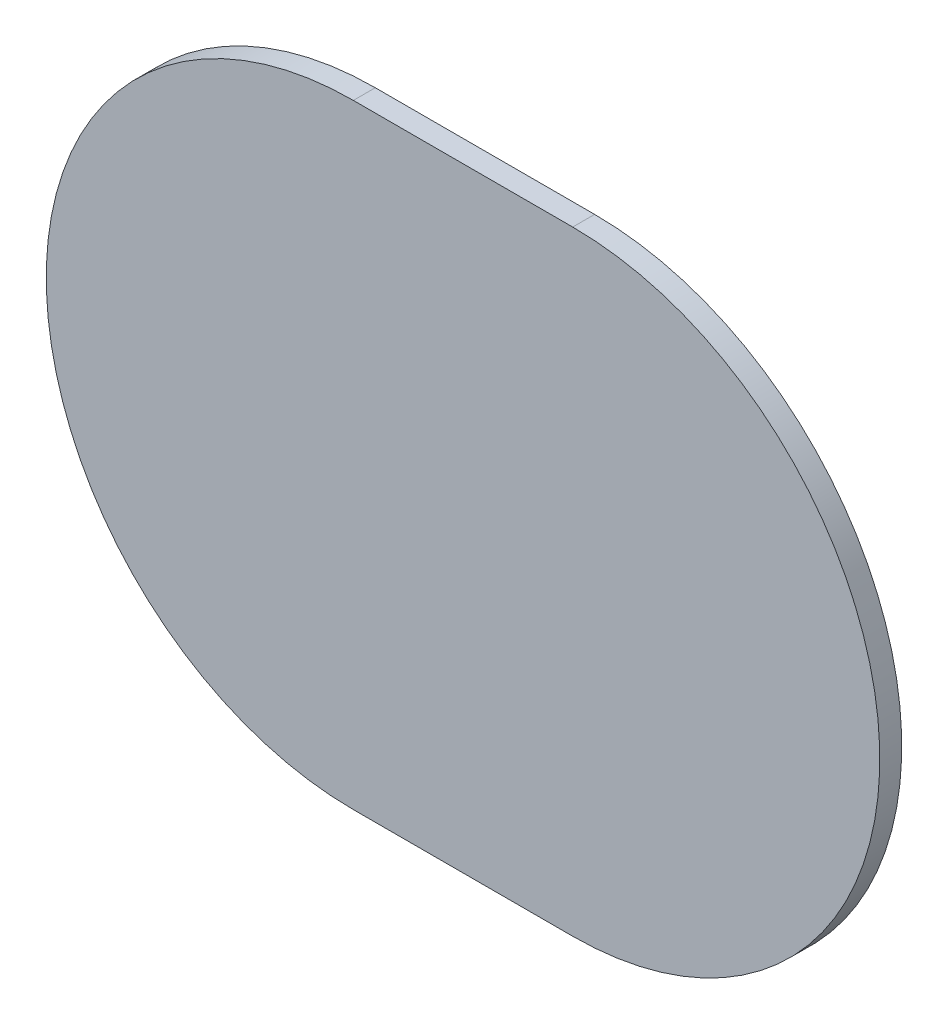
from build123d import *

# Parameters (mm, degrees)
EXTRUDE_1_DEPTH = 2


with BuildPart() as part:
    # 草图1 → 凸台-拉伸1 (new body)
    with BuildSketch(Plane.XY):
        with BuildLine():
            Line((-20, 28), (0, 28))
            ThreePointArc((0, 28), (28, 0), (0, -28))
            Line((0, -28), (-20, -28))
            ThreePointArc((-20, -28), (-48, 0), (-20, 28))
        make_face()
    extrude(amount=EXTRUDE_1_DEPTH)


solid = part.part
